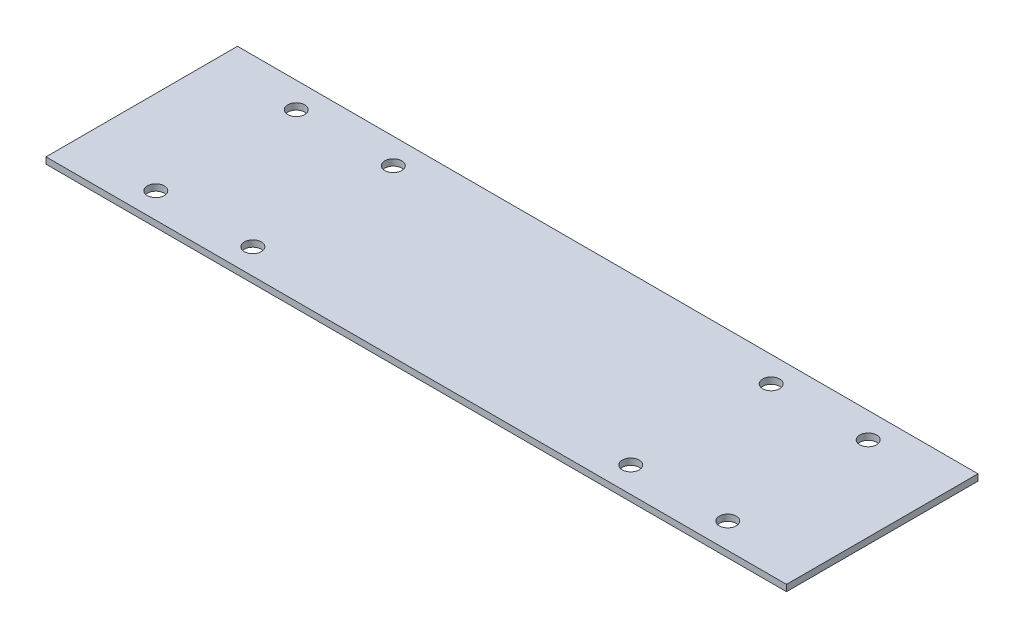
from build123d import *

# Parameters (mm, degrees)
SKETCH1_W           = 145
SKETCH1_H           = 37.5
SKETCH1_R           = 1.66
BOSS_EXTRUDE1_DEPTH = 1.25


with BuildPart() as part:
    # Sketch1 → Boss-Extrude1 (new body)
    with BuildSketch(Plane(origin=(0, 0, 0), x_dir=(1, 0, 0), z_dir=(0, 1, 0))):
        with Locations((0.941482445, 11.324772432)):
            Rectangle(SKETCH1_W, SKETCH1_H)
        with Locations(Location((-55.058517555, 25.074772432, 0), (0, 0, 270))):  # turned: the seam where the file's is
            Circle(SKETCH1_R, mode=Mode.SUBTRACT)
        with Locations(Location((-36.058517555, 25.074772432, 0), (0, 0, 270))):  # turned: the seam where the file's is
            Circle(SKETCH1_R, mode=Mode.SUBTRACT)
        with Locations(Location((-55.058517555, -2.425227568, 0), (0, 0, 270))):  # turned: the seam where the file's is
            Circle(SKETCH1_R, mode=Mode.SUBTRACT)
        with Locations(Location((-36.058517555, -2.425227568, 0), (0, 0, 270))):  # turned: the seam where the file's is
            Circle(SKETCH1_R, mode=Mode.SUBTRACT)
        with Locations(Location((37.941482445, 25.074772432, 0), (0, 0, 270))):  # turned: the seam where the file's is
            Circle(SKETCH1_R, mode=Mode.SUBTRACT)
        with Locations(Location((56.941482445, 25.074772432, 0), (0, 0, 270))):  # turned: the seam where the file's is
            Circle(SKETCH1_R, mode=Mode.SUBTRACT)
        with Locations(Location((37.941482445, -2.425227568, 0), (0, 0, 270))):  # turned: the seam where the file's is
            Circle(SKETCH1_R, mode=Mode.SUBTRACT)
        with Locations(Location((56.941482445, -2.425227568, 0), (0, 0, 270))):  # turned: the seam where the file's is
            Circle(SKETCH1_R, mode=Mode.SUBTRACT)
    extrude(amount=BOSS_EXTRUDE1_DEPTH)


solid = part.part
